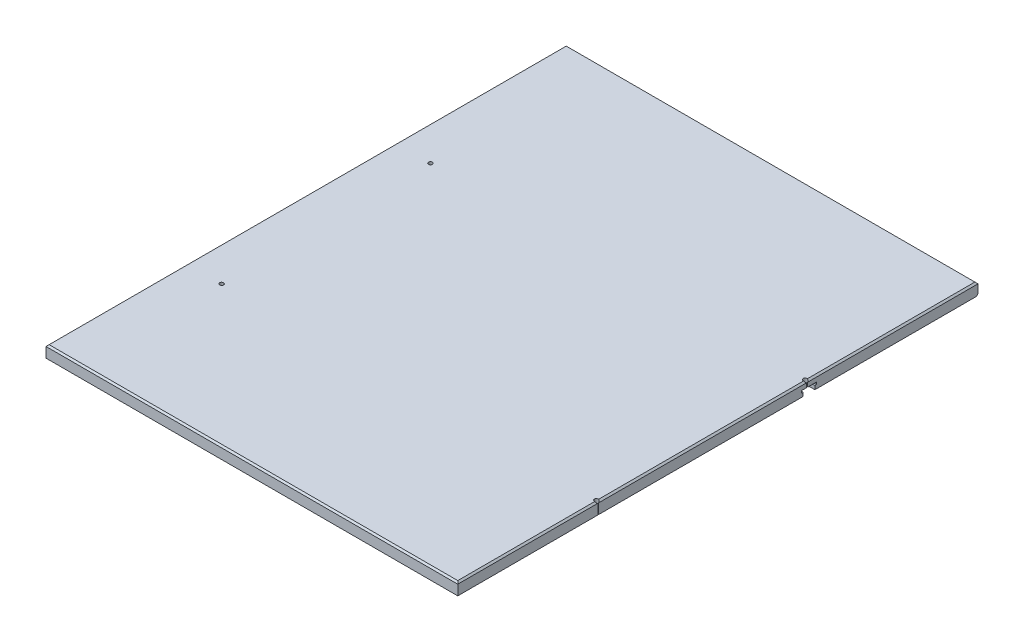
from build123d import *

# Parameters (mm, degrees)
SKETCH1_W           = 669.8488
SKETCH1_H           = 846.328
BOSS_EXTRUDE1_DEPTH = 19.05
CHAMFER1_SIZE       = 2.54
CHAMFER2_SIZE       = 2.54
CUT_EXTRUDE2_DEPTH  = 670.8488
SKETCH2_R           = 3.175
CUT_EXTRUDE3_DEPTH  = 20.05


with BuildPart() as part:
    # Sketch1 → Boss-Extrude1 (new body)
    with BuildSketch(Plane(origin=(0, 0, 0), x_dir=(1, 0, 0), z_dir=(0, 1, 0))):
        with Locations((334.9244, 423.164)):
            Rectangle(SKETCH1_W, SKETCH1_H)
    extrude(amount=BOSS_EXTRUDE1_DEPTH)

    # Chamfer1
    chamfer1_edges = [part.edges().sort_by_distance(p)[0] for p in [
        (669.8488, 19.05, -423.164),
        (334.9244, 19.05, -846.328),
        (0, 19.05, -423.164),
        (334.9244, 19.05, 0),
    ]]
    chamfer(chamfer1_edges, length=CHAMFER1_SIZE)

    # Chamfer2
    chamfer2_edges = [part.edges().sort_by_distance(p)[0] for p in [
        (334.9244, 0, -846.328),
    ]]
    chamfer(chamfer2_edges, length=CHAMFER2_SIZE)

    # Sketch3 → Cut-Extrude2 (cut, through all)
    with BuildSketch(Plane.ZY):
        Polygon((-580.93356, 5.97535), (-580.93356, 0), (-561.88356, 0), (-561.88356, 5.97535), (-559.21656, 5.97535), (-559.21656, 9.53135), (-583.60056, 9.53135), (-583.60056, 5.97535), align=None)
    extrude(amount=-CUT_EXTRUDE2_DEPTH, mode=Mode.SUBTRACT)

    # Sketch2 → Cut-Extrude3 (cut, through all)
    with BuildSketch(Plane(origin=(0, 19.05, 0), x_dir=(1, 0, 0), z_dir=(0, 1, 0))):
        with Locations((57.15, 568.325)):
            Circle(SKETCH2_R)
        with Locations((57.15, 228.6)):
            Circle(SKETCH2_R)
        with Locations((666.75, 568.325)):
            Circle(SKETCH2_R)
        with Locations((666.75, 228.6)):
            Circle(SKETCH2_R)
    extrude(amount=-CUT_EXTRUDE3_DEPTH, mode=Mode.SUBTRACT)


solid = part.part
